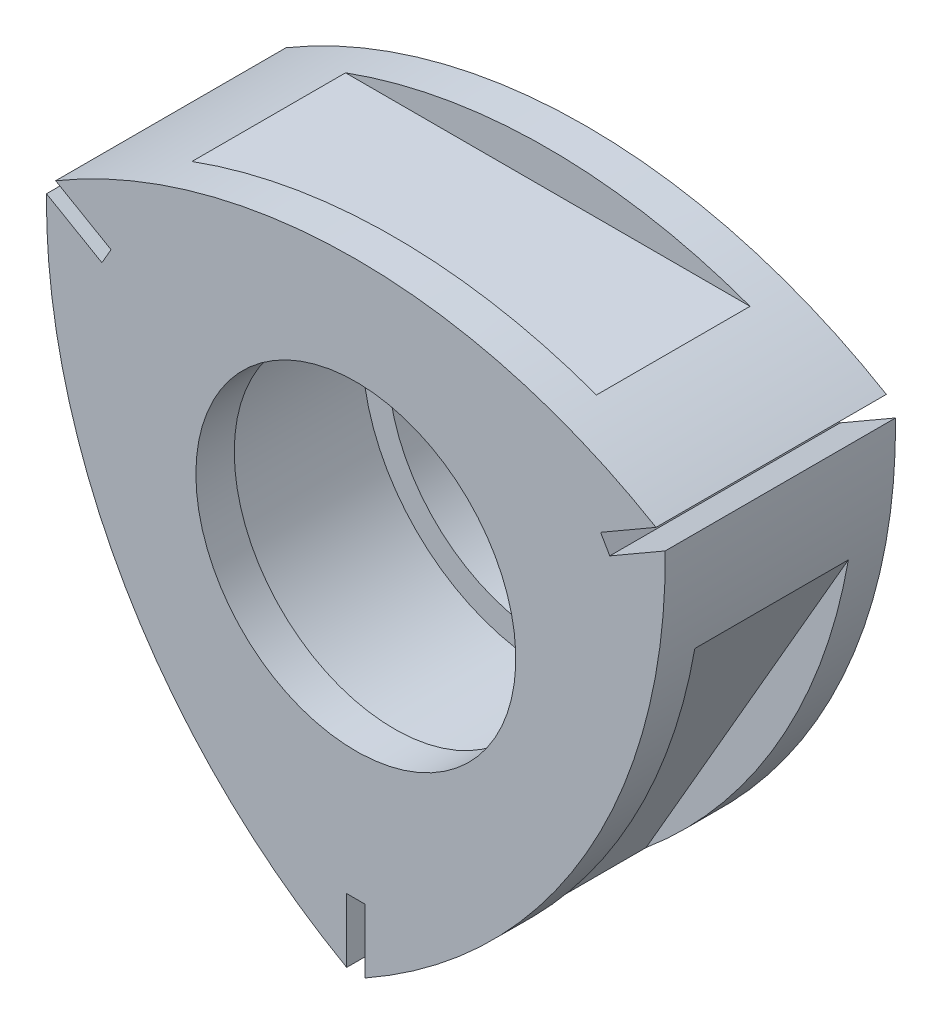
from build123d import *

# Parameters (mm, degrees)
BASE_EXTRUDE_DEPTH           = 18
COMBUSTION_CHAMBER_PROFILE_R = 14.5
CUT_EXTRUDE1_DEPTH           = 12
SKETCH6_R                    = 12.5
CUT_EXTRUDE5_DEPTH           = 19


with BuildPart() as part:
    # rotor profile → Base-Extrude (new body)
    with BuildSketch(Plane.XY):
        with BuildLine():
            Line((-24.173095266, 13.130970823), (-22.181236837, 11.980970823))
            Line((-22.181236837, 11.980970823), (-19.842968247, 10.630970823))
            Line((-19.842968247, 10.630970823), (-19.485571583, 11.250000003))
            Line((-19.485571583, 11.250000003), (-19.128174923, 11.869029177))
            Line((-19.128174923, 11.869029177), (-21.466443514, 13.219029177))
            Line((-21.466443514, 13.219029177), (-23.458301942, 14.369029177))
            ThreePointArc((-23.458301942, 14.369029177), (-12.161921268, 19.163134144), (0, 20.8))
            ThreePointArc((0, 20.8), (12.161921268, 19.163134144), (23.458301942, 14.369029177))
            Line((23.458301942, 14.369029177), (19.128174923, 11.869029177))
            Line((19.128174923, 11.869029177), (19.485571585, 11.25))
            Line((19.485571585, 11.25), (19.842968247, 10.630970823))
            Line((19.842968247, 10.630970823), (24.173095266, 13.130970823))
            ThreePointArc((24.173095266, 13.130970823), (22.676721619, 0.950965705), (18.013328399, -10.4))
            ThreePointArc((18.013328399, -10.4), (10.514800351, -20.114099849), (0.714793324, -27.5))
            Line((0.714793324, -27.5), (0.714793324, -22.5))
            Line((0.714793324, -22.5), (0, -22.5))
            Line((0, -22.5), (-0.714793324, -22.5))
            Line((-0.714793324, -22.5), (-0.714793324, -27.5))
            ThreePointArc((-0.714793324, -27.5), (-10.514800351, -20.114099849), (-18.013328399, -10.4))
            ThreePointArc((-18.013328399, -10.4), (-22.676721619, 0.950965705), (-24.173095266, 13.130970823))
        make_face()
    extrude(amount=BASE_EXTRUDE_DEPTH)

    # combustion chamber profile → Cut-Extrude1 (cut)
    with BuildSketch(Plane(origin=(0, 0, 3), x_dir=(-1, 0, 0), z_dir=(0, 0, -1))):
        Circle(COMBUSTION_CHAMBER_PROFILE_R)
        Polygon((18, 21), (18, 18), (0, 18), (-18, 18), (-18, 21), align=None)
        Polygon((-9.186533479, -26.088457268), (-27.186533479, 5.088457268), (-24.588457268, 6.588457268), (-15.588457268, -9), (-6.588457268, -24.588457268), align=None)
        Polygon((27.186533479, 5.088457268), (9.186533479, -26.088457268), (6.588457268, -24.588457268), (15.588457268, -9), (24.588457268, 6.588457268), align=None)
    extrude(amount=-CUT_EXTRUDE1_DEPTH, mode=Mode.SUBTRACT)

    # Sketch6 → Cut-Extrude5 (cut, through all)
    with BuildSketch(Plane(origin=(0, 0, 18), x_dir=(-1, 0, 0), z_dir=(0, 0, -1))):
        Circle(SKETCH6_R)
    extrude(amount=CUT_EXTRUDE5_DEPTH, mode=Mode.SUBTRACT)


solid = part.part
